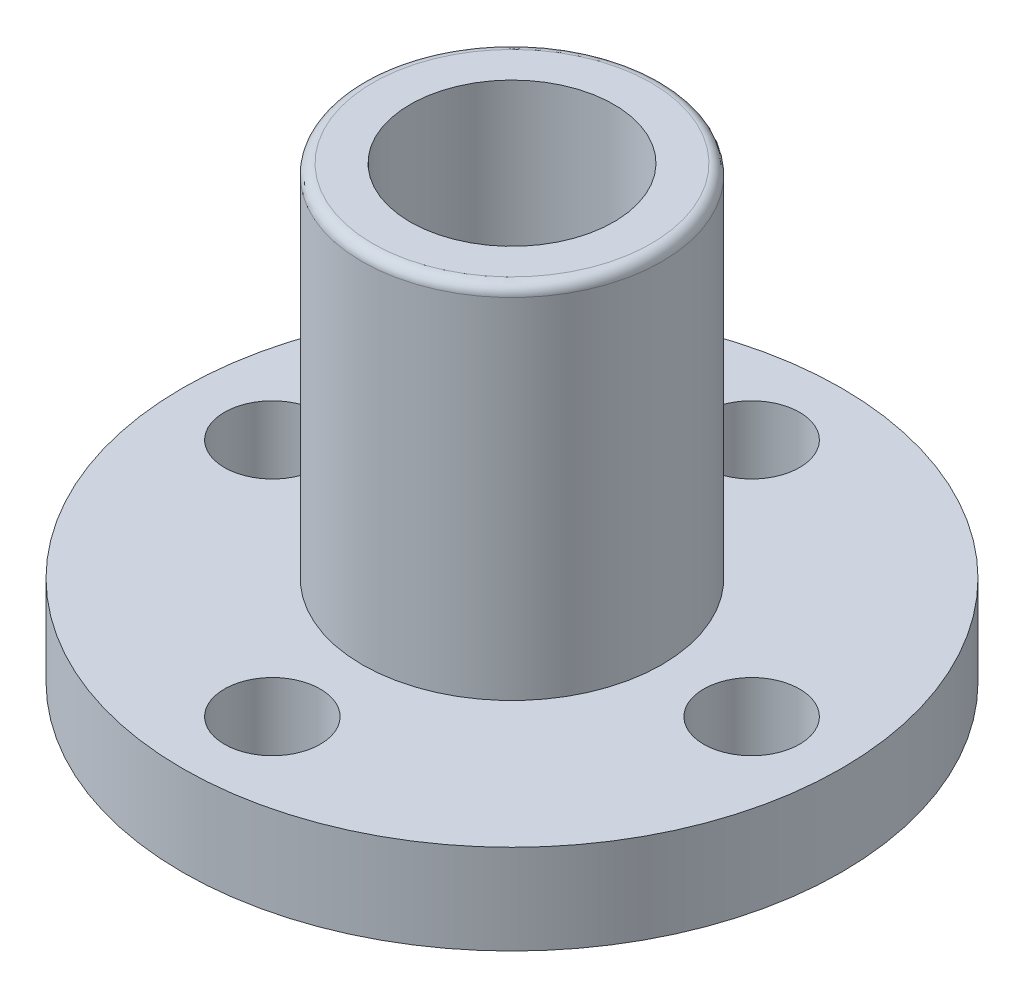
from build123d import *

# Parameters (mm, degrees)
SKETCH_1_R          = 11
EXTRUDE_1_DEPTH     = 3
SKETCH_2_R          = 5
EXTRUDE_2_DEPTH     = 12
SKETCH_5_R          = 1.6
CUT_EXTRUDE_3_DEPTH = 4
FILLET_1_R          = 0.35
SKETCH_7_R          = 5
EXTRUDE_3_DEPTH     = 1.5
HOLE_WIZARD_M8_1_D  = 6.8


with BuildPart() as part:
    # 草图1 → 凸台-拉伸1 (new body)
    with BuildSketch(Plane(origin=(0, 0, 0), x_dir=(1, 0, 0), z_dir=(0, 1, 0))):
        Circle(SKETCH_1_R)
    extrude(amount=EXTRUDE_1_DEPTH)

    # 草图2 → 凸台-拉伸2 (add)
    with BuildSketch(Plane(origin=(0, 3, 0), x_dir=(1, 0, 0), z_dir=(0, 1, 0))):
        Circle(SKETCH_2_R)
    extrude(amount=EXTRUDE_2_DEPTH)

    # 草图5 → 切除-拉伸3 (cut, through all)
    with BuildSketch(Plane(origin=(0, 3, 0), x_dir=(1, 0, 0), z_dir=(0, 1, 0))):
        with Locations((0, 8)):
            Circle(SKETCH_5_R)
        with Locations((8, 0)):
            Circle(SKETCH_5_R)
        with Locations((0, -8)):
            Circle(SKETCH_5_R)
        with Locations((-8, 0)):
            Circle(SKETCH_5_R)
    extrude(amount=-CUT_EXTRUDE_3_DEPTH, mode=Mode.SUBTRACT)

    # 圆角1
    fillet_1_edges = [part.edges().sort_by_distance(p)[0] for p in [
        (-5, 15, 0),
    ]]
    fillet(fillet_1_edges, radius=FILLET_1_R)

    # 草图7 → 凸台-拉伸3 (add)
    with BuildSketch(Plane.XZ):
        Circle(SKETCH_7_R)
    extrude(amount=EXTRUDE_3_DEPTH)

    # M8 螺纹孔1 (through all)
    with Locations(Plane(origin=(0, 15, 0), x_dir=(1, 0, 0), z_dir=(0, 1, 0))):
        with Locations((0, 0)):
            Hole(HOLE_WIZARD_M8_1_D / 2)


solid = part.part
